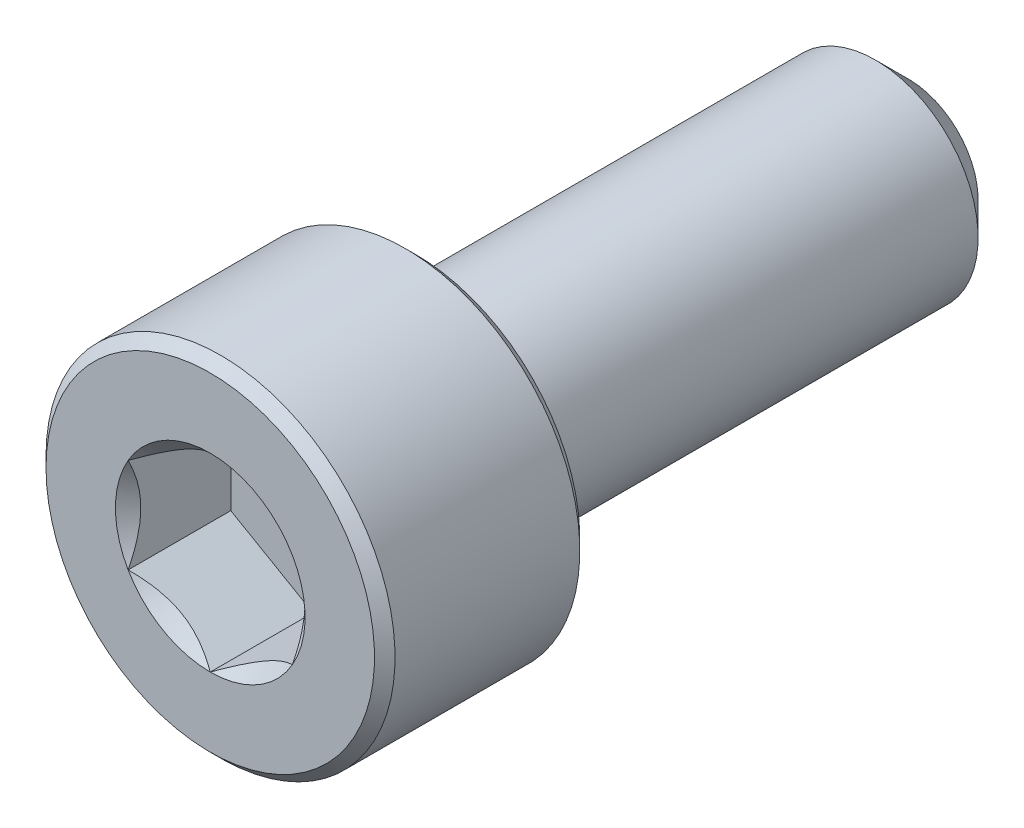
from build123d import *

# Parameters (mm, degrees)
CUT_EXTRUDE1_START = -2.5
CUT_EXTRUDE1_DEPTH = 2.5
SKETCH4_R          = 2.309401077
CUT_EXTRUDE2_DEPTH = 0.5
CUT_EXTRUDE2_TAPER = 45


with BuildPart() as part:
    # Sketch2 → Revolve1 (revolve)
    with BuildSketch(Plane(origin=(0, 0, 0), x_dir=(0, 0, -1), z_dir=(1, 0, 0))):
        Polygon((-8.25, 4.25), (-3.75, 4.25), (-3.5, 4), (-3.5, 2.5), (7.7, 2.5), (8.5, 1.7), (8.5, 0), (-8.5, 0), (-8.5, 4), align=None)
    revolve(axis=Axis((0, 0, -8.5), (0, 0, 1)))

    # Sketch3 → Cut-Extrude1 (cut)
    with BuildSketch(Plane.XY.offset(8.5).offset(CUT_EXTRUDE1_START)):
        Polygon((0, 2.309401077), (-2, 1.154700538), (-2, -1.154700538), (0, -2.309401077), (2, -1.154700538), (2, 1.154700538), align=None)
    extrude(amount=CUT_EXTRUDE1_DEPTH, mode=Mode.SUBTRACT)

    # Sketch4 → Cut-Extrude2 (cut)
    with BuildSketch(Plane.XY.offset(8.5)):
        Circle(SKETCH4_R)
    extrude(amount=-CUT_EXTRUDE2_DEPTH, taper=CUT_EXTRUDE2_TAPER, mode=Mode.SUBTRACT)


solid = part.part
